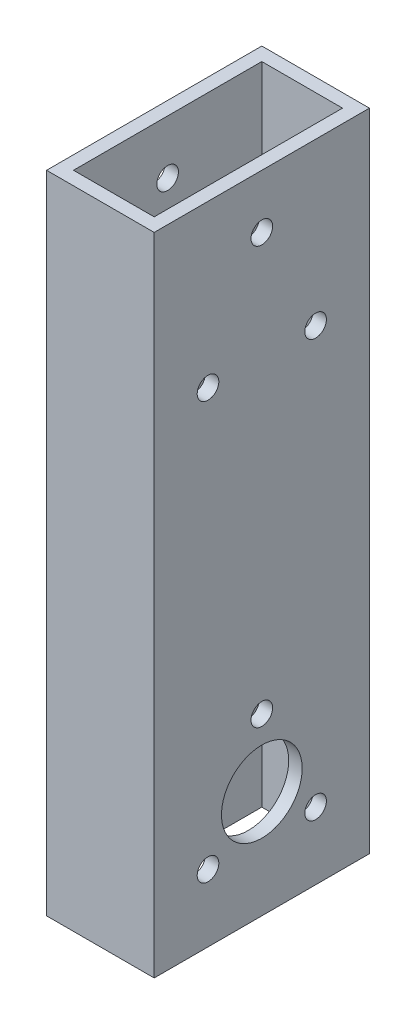
from build123d import *

# Parameters (mm, degrees)
SKETCH1_W           = 25.4
SKETCH1_H           = 50.8
SKETCH1_W_2         = 19.05
SKETCH1_H_2         = 44.45
BOSS_EXTRUDE1_DEPTH = 152.4
SKETCH2_R           = 2.5527
CUT_EXTRUDE1_DEPTH  = 50.8
SKETCH3_R           = 9.525
CUT_EXTRUDE2_DEPTH  = 25.4


with BuildPart() as part:
    # Sketch1 → Boss-Extrude1 (new body)
    with BuildSketch(Plane(origin=(0, 0, 0), x_dir=(1, 0, 0), z_dir=(0, 1, 0))):
        with Locations((12.7, 25.4)):
            Rectangle(SKETCH1_W, SKETCH1_H)
        with Locations((12.7, 25.4)):
            Rectangle(SKETCH1_W_2, SKETCH1_H_2, mode=Mode.SUBTRACT)
    extrude(amount=BOSS_EXTRUDE1_DEPTH)

    # Sketch2 → Cut-Extrude1 (cut)
    with BuildSketch(Plane(origin=(25.4, 0, 0), x_dir=(0, 0, -1), z_dir=(1, 0, 0))):
        with Locations((25.4, 139.7)):
            Circle(SKETCH2_R)
        with Locations((12.7, 114.3)):
            Circle(SKETCH2_R)
        with Locations((38.1, 114.3)):
            Circle(SKETCH2_R)
        with Locations((25.4, 41.275)):
            Circle(SKETCH2_R)
        with Locations((12.7, 15.875)):
            Circle(SKETCH2_R)
        with Locations((38.1, 15.875)):
            Circle(SKETCH2_R)
    extrude(amount=-CUT_EXTRUDE1_DEPTH, mode=Mode.SUBTRACT)

    # Sketch3 → Cut-Extrude2 (cut)
    with BuildSketch(Plane(origin=(25.4, 0, 0), x_dir=(0, 0, -1), z_dir=(1, 0, 0))):
        with Locations((25.4, 25.4)):
            Circle(SKETCH3_R)
    extrude(amount=-CUT_EXTRUDE2_DEPTH, mode=Mode.SUBTRACT)


solid = part.part
